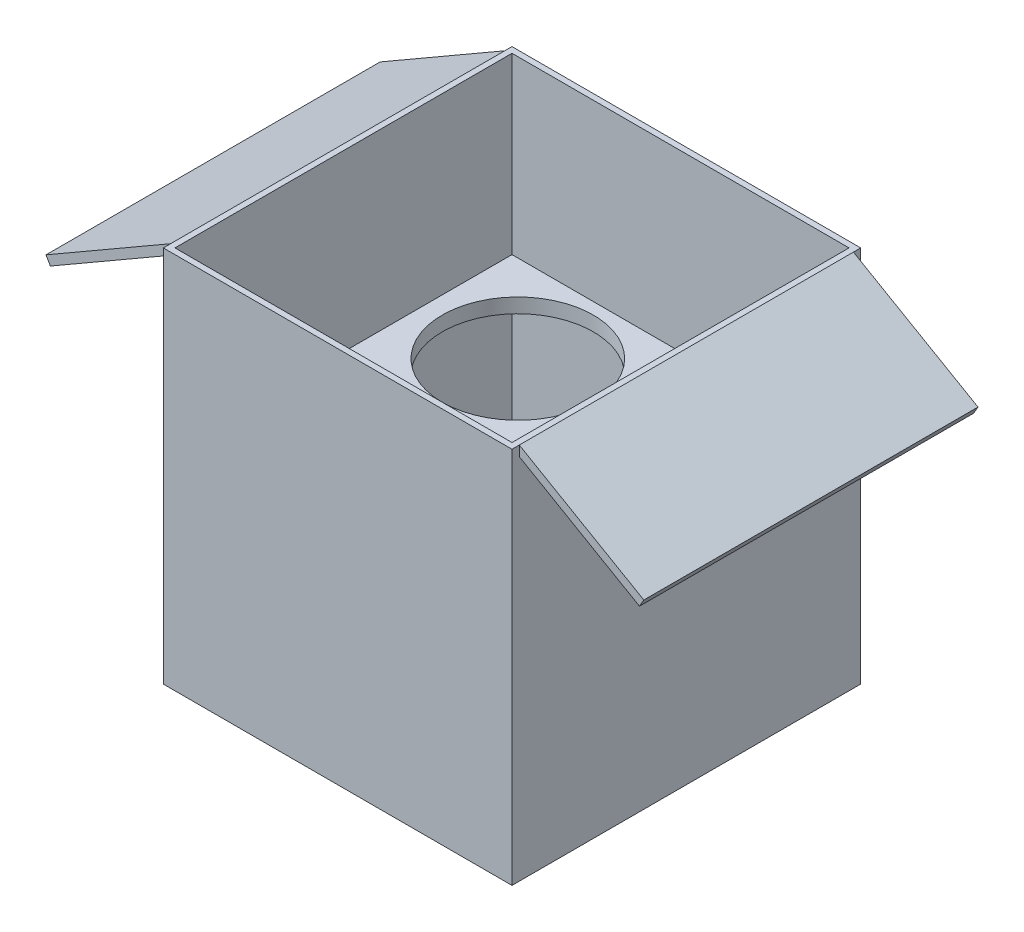
from build123d import *

# Parameters (mm, degrees)
SKETCH1_W           = 120
SKETCH1_H           = 120
BOSS_EXTRUDE1_DEPTH = 5
SKETCH1_3_W         = 120
SKETCH1_3_H         = 120
SKETCH1_3_W_2       = 116
SKETCH1_3_H_2       = 116
BOSS_EXTRUDE2_DEPTH = 130
BOSS_EXTRUDE3_DEPTH = 57.5
SKETCH4_W           = 120
SKETCH4_H           = 5
BOSS_EXTRUDE4_DEPTH = 118
SKETCH5_R           = 26
CUT_EXTRUDE1_DEPTH  = 10


with BuildPart() as part:
    # Sketch1 → Boss-Extrude1 (new body)
    with BuildSketch(Plane(origin=(0, 0, 0), x_dir=(1, 0, 0), z_dir=(0, 1, 0))):
        Rectangle(SKETCH1_W, SKETCH1_H)
    extrude(amount=BOSS_EXTRUDE1_DEPTH)

    # Sketch1_3 → Boss-Extrude2 (add)
    with BuildSketch(Plane(origin=(0, 0, 0), x_dir=(1, 0, 0), z_dir=(0, 1, 0))):
        Rectangle(SKETCH1_3_W, SKETCH1_3_H)
        Rectangle(SKETCH1_3_W_2, SKETCH1_3_H_2, mode=Mode.SUBTRACT)
    extrude(amount=BOSS_EXTRUDE2_DEPTH)

    # Sketch2 → Boss-Extrude3 (add, symmetric)
    with BuildSketch(Plane.XY):
        Polygon((60, 130), (102.868257487, 105.25), (101.368257487, 102.651923789), (60, 126.535898385), align=None)
    boss_extrude3 = extrude(amount=BOSS_EXTRUDE3_DEPTH, both=True)

    # Mirror1: Boss-Extrude3 across plane
    add(boss_extrude3.mirror(Plane(origin=(0, 0, 0), x_dir=(0, 0, 1), z_dir=(1, 0, 0))))

    # Sketch4 → Boss-Extrude4 (add)
    with BuildSketch(Plane.XY.offset(-58)):
        with Locations((0, 67.5)):
            Rectangle(SKETCH4_W, SKETCH4_H)
    extrude(amount=BOSS_EXTRUDE4_DEPTH)

    # Sketch5 → Cut-Extrude1 (cut)
    with BuildSketch(Plane(origin=(0, 70, 0), x_dir=(1, 0, 0), z_dir=(0, 1, 0))):
        with Locations((28, 28)):
            Circle(SKETCH5_R)
        with Locations((-26, 28)):
            Circle(SKETCH5_R)
        with Locations((28, -28)):
            Circle(SKETCH5_R)
        with Locations((-26, -28)):
            Circle(SKETCH5_R)
    extrude(amount=-CUT_EXTRUDE1_DEPTH, mode=Mode.SUBTRACT)


solid = part.part
